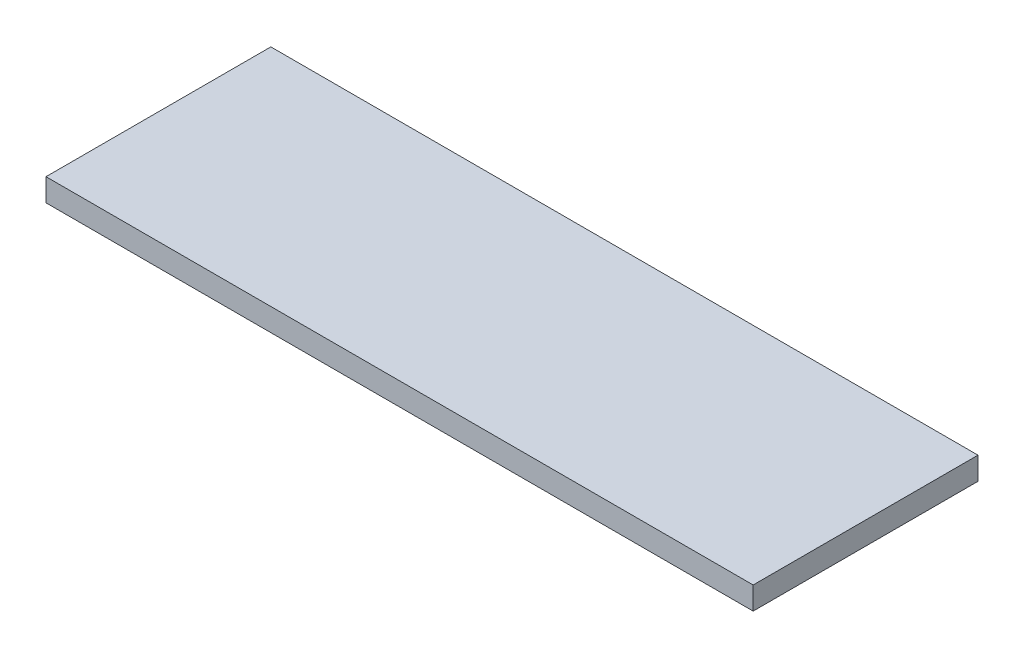
from build123d import *

# Parameters (mm, degrees)
SKETCH1_W           = 198.12
SKETCH1_H           = 62.992
BOSS_EXTRUDE1_DEPTH = 6.35


with BuildPart() as part:
    # Sketch1 → Boss-Extrude1 (new body)
    with BuildSketch(Plane(origin=(0, 0, 0), x_dir=(1, 0, 0), z_dir=(0, 1, 0))):
        Rectangle(SKETCH1_W, SKETCH1_H)
    extrude(amount=BOSS_EXTRUDE1_DEPTH)


solid = part.part
